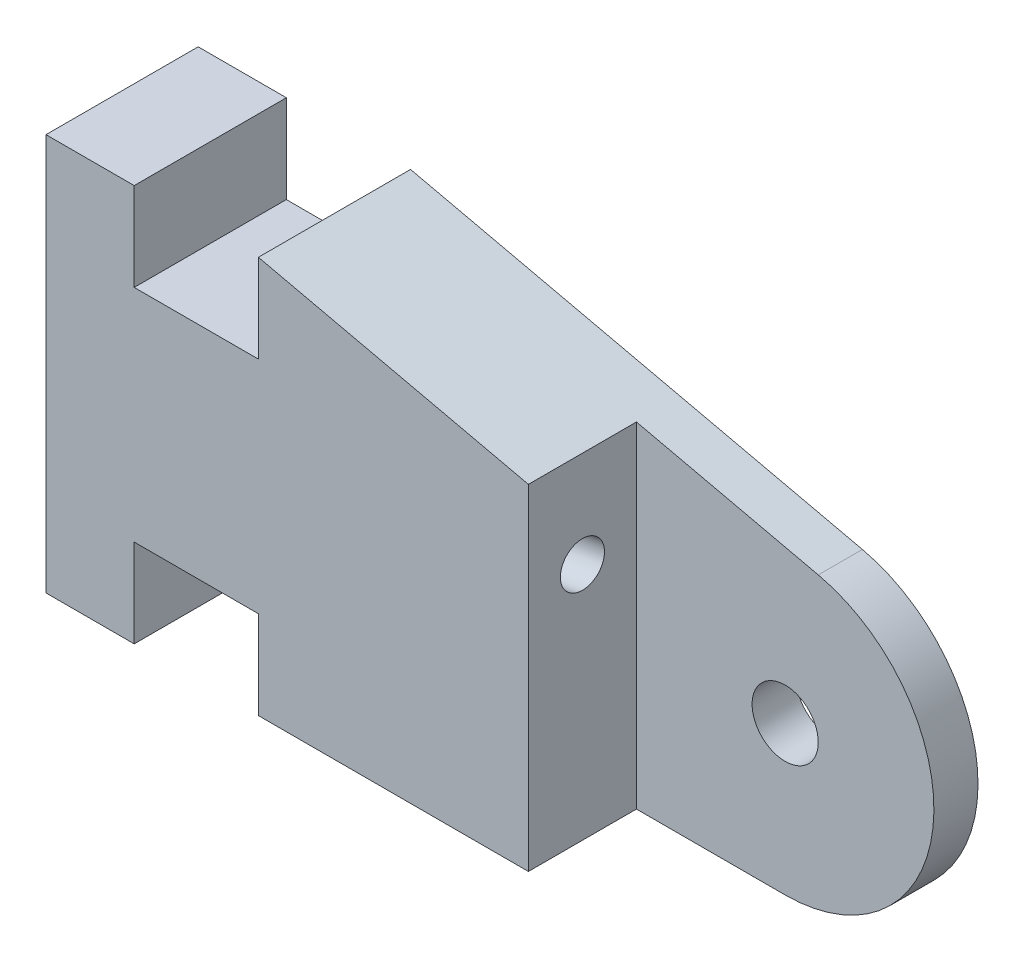
from build123d import *

# Parameters (mm, degrees)
SKETCH1_R               = 1.5
BOSS_EXTRUDE1_DEPTH     = 6.9
CUT_EXTRUDE2_START      = -4.9
CUT_EXTRUDE2_DEPTH      = 4.9
SKETCH5_R               = 1
CUT_EXTRUDE3_DEPTH      = 7
CUT_EXTRUDE4_DEPTH      = 1
CUT_EXTRUDE4_DEPTH_BACK = 32.830268668
SKETCH7_R               = 1


with BuildPart() as part:
    # Sketch1 → Boss-Extrude1 (new body)
    with BuildSketch(Plane.XY):
        with BuildLine():
            Line((0, 0), (0, 18.000341084))
            Line((0, 18.000341084), (4, 18.000341084))
            Line((4, 18.000341084), (4, 14.000341084))
            Line((4, 14.000341084), (9.631516349, 14.000341084))
            Line((9.631516349, 14.000341084), (9.631516349, 18.000341084))
            Line((9.631516349, 18.000341084), (30.123176491, 13.320805491))
            ThreePointArc((30.123176491, 13.320805491), (35.324106187, 5.989458303), (28.621516349, 0))
            Line((28.621516349, 0), (9.631516349, 0))
            Line((9.631516349, 0), (9.631516349, 4))
            Line((9.631516349, 4), (4, 4))
            Line((4, 4), (4, 0))
            Line((4, 0), (0, 0))
        make_face()
        with Locations((28.621516349, 6.745044143)):
            Circle(SKETCH1_R, mode=Mode.SUBTRACT)
    extrude(amount=BOSS_EXTRUDE1_DEPTH)

    # Sketch4 → Cut-Extrude2 (cut)
    with BuildSketch(Plane.XY.offset(6.9).offset(CUT_EXTRUDE2_START)):
        with BuildLine():
            Line((21.876472206, 0), (21.876472206, 15.204047061))
            Line((21.876472206, 15.204047061), (30.123176491, 13.320805491))
            ThreePointArc((30.123176491, 13.320805491), (35.324106187, 5.989458303), (28.621516349, 0))
            Line((28.621516349, 0), (21.876472206, 0))
        make_face()
    extrude(amount=CUT_EXTRUDE2_DEPTH, mode=Mode.SUBTRACT)

    # Sketch5 → Cut-Extrude3 (cut)
    with BuildSketch(Plane.ZY):
        with Locations((4.45, 8)):
            Circle(SKETCH5_R)
    extrude(amount=-CUT_EXTRUDE3_DEPTH, mode=Mode.SUBTRACT)

    # Sketch7 → Cut-Extrude4 (cut, two sides: drawn at the far end of the back side and taken through both)
    with BuildSketch(Plane(origin=(8.983585976, 1.584048591, 0), x_dir=(0, 0, 1), z_dir=(-0.9848077530122079, -0.17364817766693139, 0)).offset(-CUT_EXTRUDE4_DEPTH_BACK)):
        with Locations((4.45, 6.87)):
            Circle(SKETCH7_R)
    extrude(amount=CUT_EXTRUDE4_DEPTH + CUT_EXTRUDE4_DEPTH_BACK, mode=Mode.SUBTRACT)


solid = part.part
